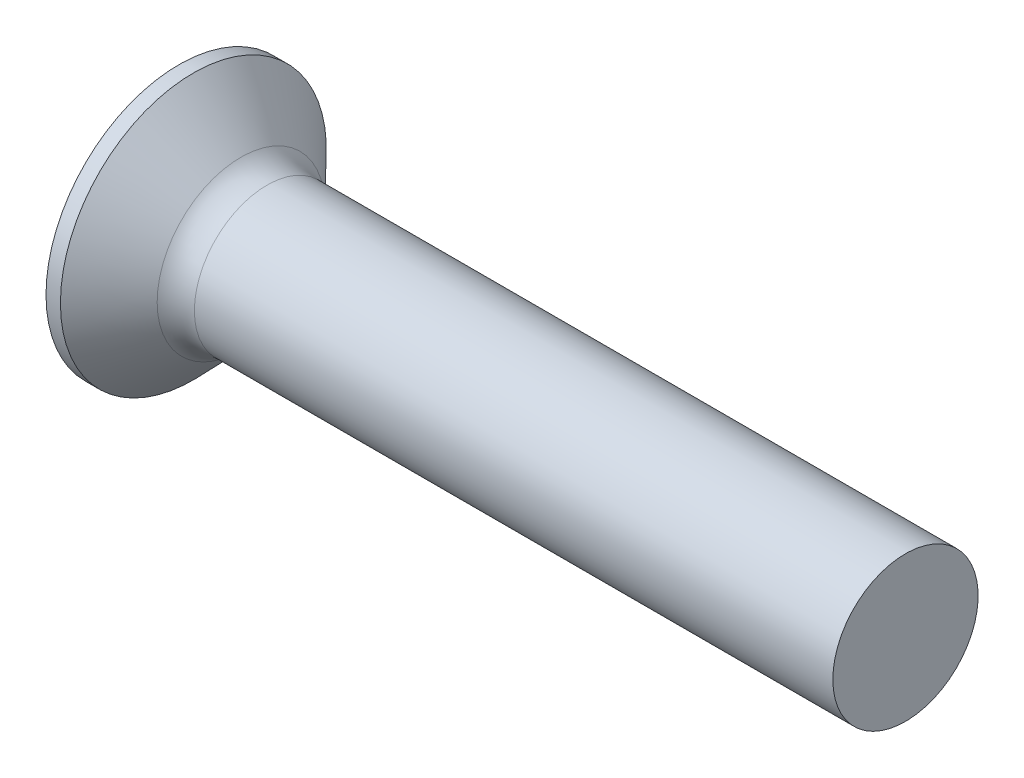
from build123d import *

# Parameters (mm, degrees)
FILLET1_R    = 2.5
SKETCH3_W    = 2.16
SKETCH3_H    = 9.8
SKETCH4_W    = 2.16
SKETCH4_H    = 4.176000402
RECPAT_COUNT = 2
RECPAT_ANGLE = 90


with BuildPart() as part:
    # BodySke → Base-Revolve (revolve)
    with BuildSketch(Plane.XY):
        Polygon((0, 0), (0, 9.15), (0.992391585, 9.15), (5, 5), (50, 5), (50, 0), align=None)
    revolve(axis=Axis((-6.35, 0, 0), (1, 0, 0)))

    # Fillet1
    fillet1_edges = [part.edges().sort_by_distance(p)[0] for p in [
        (5, -5, 0),
    ]]
    fillet(fillet1_edges, radius=FILLET1_R)

    # Sketch3 → Recess section 0
    with BuildSketch(Plane.ZY):
        Rectangle(SKETCH3_W, SKETCH3_H)
    # Sketch4 → Recess section 1
    with BuildSketch(Plane.ZY.offset(-5.64)):
        Rectangle(SKETCH4_W, SKETCH4_H)
    recess = loft(mode=Mode.SUBTRACT)

    # RecPat: Recess ×2 about axis
    recpat_axis = Axis((0, 0, 0), (1, 0, 0))
    for i in range(1, RECPAT_COUNT):
        add(recess.rotate(recpat_axis, i * RECPAT_ANGLE / (RECPAT_COUNT - 1)), mode=Mode.SUBTRACT)

    # RecCorSke → RecessCore (revolve, cut)
    with BuildSketch(Plane.XY):
        Polygon((0, 0), (0, 2.324887219), (5.64, 1.9305), (6.267257474, 0), align=None)
    revolve(axis=Axis((-3.175, 0, 0), (1, 0, 0)), mode=Mode.SUBTRACT)


solid = part.part
